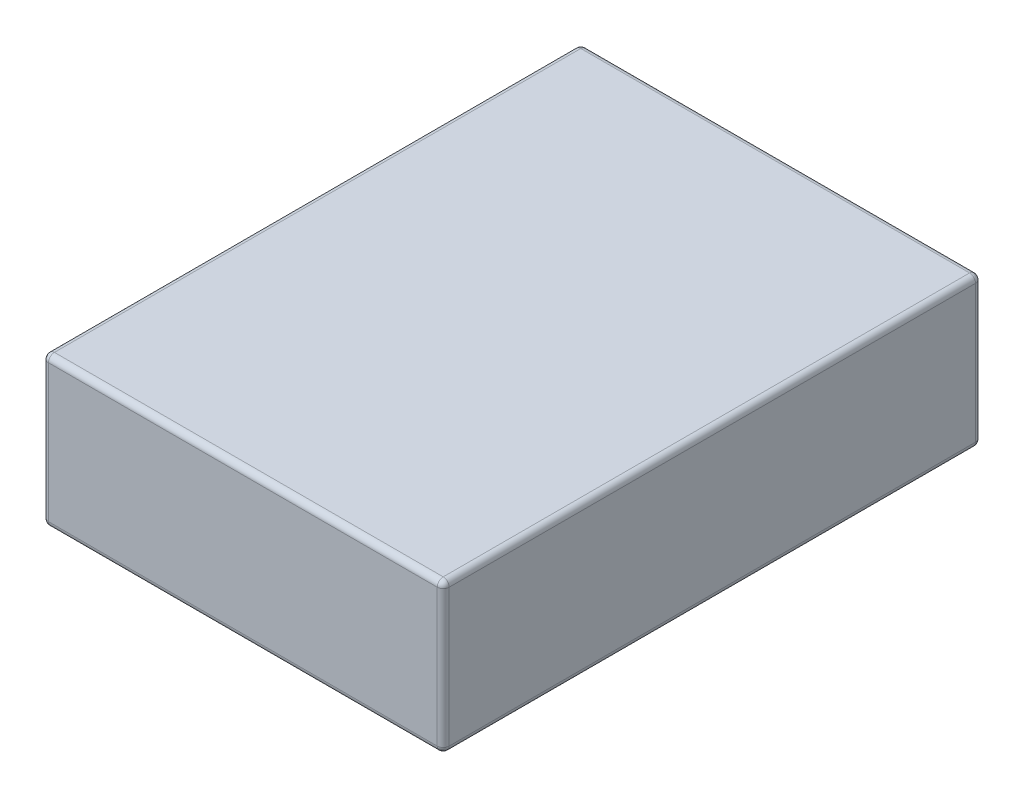
from build123d import *

# Parameters (mm, degrees)
SKETCH1_W           = 67
SKETCH1_H           = 90
BOSS_EXTRUDE1_DEPTH = 25
FILLET1_R           = 1


with BuildPart() as part:
    # Sketch1 → Boss-Extrude1 (new body)
    with BuildSketch(Plane(origin=(0, 0, 0), x_dir=(1, 0, 0), z_dir=(0, 1, 0))):
        Rectangle(SKETCH1_W, SKETCH1_H)
    extrude(amount=BOSS_EXTRUDE1_DEPTH)

    # Fillet1
    fillet1_edges = [part.edges().sort_by_distance(p)[0] for p in [
        (-33.5, 25, 0),
        (0, 25, 45),
        (33.5, 25, 0),
        (0, 0, 45),
        (-33.5, 0, 0),
        (0, 0, -45),
        (33.5, 0, 0),
        (33.5, 12.5, 45),
        (-33.5, 12.5, 45),
        (-33.5, 12.5, -45),
        (33.5, 12.5, -45),
        (0, 25, -45),
    ]]
    fillet(fillet1_edges, radius=FILLET1_R)


solid = part.part
